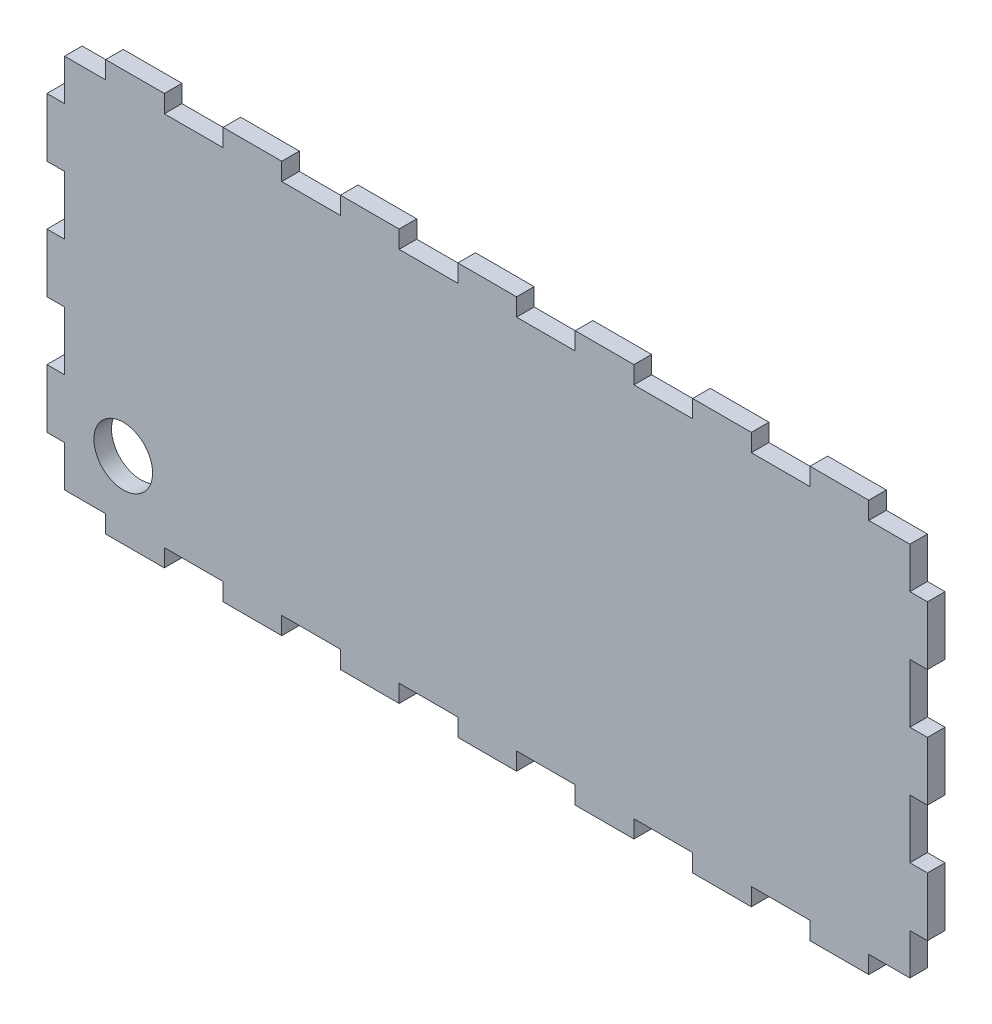
from build123d import *

# Parameters (mm, degrees)
SKETCH1_W               = 150
SKETCH1_H               = 70
BOSS_EXTRUDE1_DEPTH     = 3
SKETCH2_W               = 10
SKETCH2_H               = 3
CUT_EXTRUDE1_DEPTH      = 3
LPATTERN3_COUNT         = 8
LPATTERN3_PITCH         = 20
MIRROR1_COPY_1_SKETCH_W = 10
MIRROR1_COPY_1_SKETCH_H = 3
MIRROR1_COPY_1_DEPTH    = 3
MIRROR1_COPY_2_SKETCH_W = 10
MIRROR1_COPY_2_SKETCH_H = 3
MIRROR1_COPY_2_DEPTH    = 3
MIRROR1_COPY_3_SKETCH_W = 10
MIRROR1_COPY_3_SKETCH_H = 3
MIRROR1_COPY_3_DEPTH    = 3
MIRROR1_COPY_4_SKETCH_W = 10
MIRROR1_COPY_4_SKETCH_H = 3
MIRROR1_COPY_4_DEPTH    = 3
MIRROR1_COPY_5_SKETCH_W = 10
MIRROR1_COPY_5_SKETCH_H = 3
MIRROR1_COPY_5_DEPTH    = 3
MIRROR1_COPY_6_SKETCH_W = 10
MIRROR1_COPY_6_SKETCH_H = 3
MIRROR1_COPY_6_DEPTH    = 3
MIRROR1_COPY_7_SKETCH_W = 10
MIRROR1_COPY_7_SKETCH_H = 3
MIRROR1_COPY_7_DEPTH    = 3
SKETCH3_W               = 3
SKETCH3_H               = 10
CUT_EXTRUDE2_DEPTH      = 3
LPATTERN4_COUNT         = 4
LPATTERN4_PITCH         = 20
MIRROR2_COPY_1_SKETCH_W = 3
MIRROR2_COPY_1_SKETCH_H = 10
MIRROR2_COPY_1_DEPTH    = 3
MIRROR2_COPY_2_SKETCH_W = 3
MIRROR2_COPY_2_SKETCH_H = 10
MIRROR2_COPY_2_DEPTH    = 3
MIRROR2_COPY_3_SKETCH_W = 3
MIRROR2_COPY_3_SKETCH_H = 10
MIRROR2_COPY_3_DEPTH    = 3
SKETCH6_R               = 5
CUT_EXTRUDE3_DEPTH      = 3


with BuildPart() as part:
    # Sketch1 → Boss-Extrude1 (new body)
    with BuildSketch(Plane.XY):
        Rectangle(SKETCH1_W, SKETCH1_H)
    extrude(amount=BOSS_EXTRUDE1_DEPTH)

    # Sketch2 → Cut-Extrude1 (cut)
    with BuildSketch(Plane.XY.offset(3)):
        with Locations((-70, 33.5)):
            Rectangle(SKETCH2_W, SKETCH2_H)
    cut_extrude1 = extrude(amount=-CUT_EXTRUDE1_DEPTH, mode=Mode.SUBTRACT)

    # LPattern3: Cut-Extrude1 ×8
    with Locations(*[(i * LPATTERN3_PITCH, 0, 0) for i in range(1, LPATTERN3_COUNT)]):
        add(cut_extrude1, mode=Mode.SUBTRACT)

    # Mirror1: Cut-Extrude1 across plane
    add(cut_extrude1.mirror(Plane.ZX), mode=Mode.SUBTRACT)

    # Mirror1 copy 1 sketch → Mirror1 copy 1 (cut)
    with BuildSketch(Plane(origin=(20, 0, 3), x_dir=(1, 0, 0), z_dir=(0, 0, 1))):
        with Locations((-70, -33.5)):
            Rectangle(MIRROR1_COPY_1_SKETCH_W, MIRROR1_COPY_1_SKETCH_H)
    extrude(amount=-MIRROR1_COPY_1_DEPTH, mode=Mode.SUBTRACT)

    # Mirror1 copy 2 sketch → Mirror1 copy 2 (cut)
    with BuildSketch(Plane(origin=(40, 0, 3), x_dir=(1, 0, 0), z_dir=(0, 0, 1))):
        with Locations((-70, -33.5)):
            Rectangle(MIRROR1_COPY_2_SKETCH_W, MIRROR1_COPY_2_SKETCH_H)
    extrude(amount=-MIRROR1_COPY_2_DEPTH, mode=Mode.SUBTRACT)

    # Mirror1 copy 3 sketch → Mirror1 copy 3 (cut)
    with BuildSketch(Plane(origin=(60, 0, 3), x_dir=(1, 0, 0), z_dir=(0, 0, 1))):
        with Locations((-70, -33.5)):
            Rectangle(MIRROR1_COPY_3_SKETCH_W, MIRROR1_COPY_3_SKETCH_H)
    extrude(amount=-MIRROR1_COPY_3_DEPTH, mode=Mode.SUBTRACT)

    # Mirror1 copy 4 sketch → Mirror1 copy 4 (cut)
    with BuildSketch(Plane(origin=(80, 0, 3), x_dir=(1, 0, 0), z_dir=(0, 0, 1))):
        with Locations((-70, -33.5)):
            Rectangle(MIRROR1_COPY_4_SKETCH_W, MIRROR1_COPY_4_SKETCH_H)
    extrude(amount=-MIRROR1_COPY_4_DEPTH, mode=Mode.SUBTRACT)

    # Mirror1 copy 5 sketch → Mirror1 copy 5 (cut)
    with BuildSketch(Plane(origin=(100, 0, 3), x_dir=(1, 0, 0), z_dir=(0, 0, 1))):
        with Locations((-70, -33.5)):
            Rectangle(MIRROR1_COPY_5_SKETCH_W, MIRROR1_COPY_5_SKETCH_H)
    extrude(amount=-MIRROR1_COPY_5_DEPTH, mode=Mode.SUBTRACT)

    # Mirror1 copy 6 sketch → Mirror1 copy 6 (cut)
    with BuildSketch(Plane(origin=(120, 0, 3), x_dir=(1, 0, 0), z_dir=(0, 0, 1))):
        with Locations((-70, -33.5)):
            Rectangle(MIRROR1_COPY_6_SKETCH_W, MIRROR1_COPY_6_SKETCH_H)
    extrude(amount=-MIRROR1_COPY_6_DEPTH, mode=Mode.SUBTRACT)

    # Mirror1 copy 7 sketch → Mirror1 copy 7 (cut)
    with BuildSketch(Plane(origin=(140, 0, 3), x_dir=(1, 0, 0), z_dir=(0, 0, 1))):
        with Locations((-70, -33.5)):
            Rectangle(MIRROR1_COPY_7_SKETCH_W, MIRROR1_COPY_7_SKETCH_H)
    extrude(amount=-MIRROR1_COPY_7_DEPTH, mode=Mode.SUBTRACT)

    # Sketch3 → Cut-Extrude2 (cut)
    with BuildSketch(Plane.XY.offset(3)):
        with Locations((-73.5, 30)):
            Rectangle(SKETCH3_W, SKETCH3_H)
    cut_extrude2 = extrude(amount=-CUT_EXTRUDE2_DEPTH, mode=Mode.SUBTRACT)

    # LPattern4: Cut-Extrude2 ×4
    with Locations(*[(0, -i * LPATTERN4_PITCH, 0) for i in range(1, LPATTERN4_COUNT)]):
        add(cut_extrude2, mode=Mode.SUBTRACT)

    # Mirror2: Cut-Extrude2 across plane
    add(cut_extrude2.mirror(Plane(origin=(0, 0, 0), x_dir=(0, 0, 1), z_dir=(1, 0, 0))), mode=Mode.SUBTRACT)

    # Mirror2 copy 1 sketch → Mirror2 copy 1 (cut)
    with BuildSketch(Plane(origin=(0, -20, 3), x_dir=(-1, 0, 0), z_dir=(0, 0, 1))):
        with Locations((-73.5, -30)):
            Rectangle(MIRROR2_COPY_1_SKETCH_W, MIRROR2_COPY_1_SKETCH_H)
    extrude(amount=-MIRROR2_COPY_1_DEPTH, mode=Mode.SUBTRACT)

    # Mirror2 copy 2 sketch → Mirror2 copy 2 (cut)
    with BuildSketch(Plane(origin=(0, -40, 3), x_dir=(-1, 0, 0), z_dir=(0, 0, 1))):
        with Locations((-73.5, -30)):
            Rectangle(MIRROR2_COPY_2_SKETCH_W, MIRROR2_COPY_2_SKETCH_H)
    extrude(amount=-MIRROR2_COPY_2_DEPTH, mode=Mode.SUBTRACT)

    # Mirror2 copy 3 sketch → Mirror2 copy 3 (cut)
    with BuildSketch(Plane(origin=(0, -60, 3), x_dir=(-1, 0, 0), z_dir=(0, 0, 1))):
        with Locations((-73.5, -30)):
            Rectangle(MIRROR2_COPY_3_SKETCH_W, MIRROR2_COPY_3_SKETCH_H)
    extrude(amount=-MIRROR2_COPY_3_DEPTH, mode=Mode.SUBTRACT)

    # Sketch6 → Cut-Extrude3 (cut)
    with BuildSketch(Plane(origin=(0, 0, 0), x_dir=(-1, 0, 0), z_dir=(0, 0, -1))):
        with Locations((62, -22)):
            Circle(SKETCH6_R)
    extrude(amount=-CUT_EXTRUDE3_DEPTH, mode=Mode.SUBTRACT)


solid = part.part
